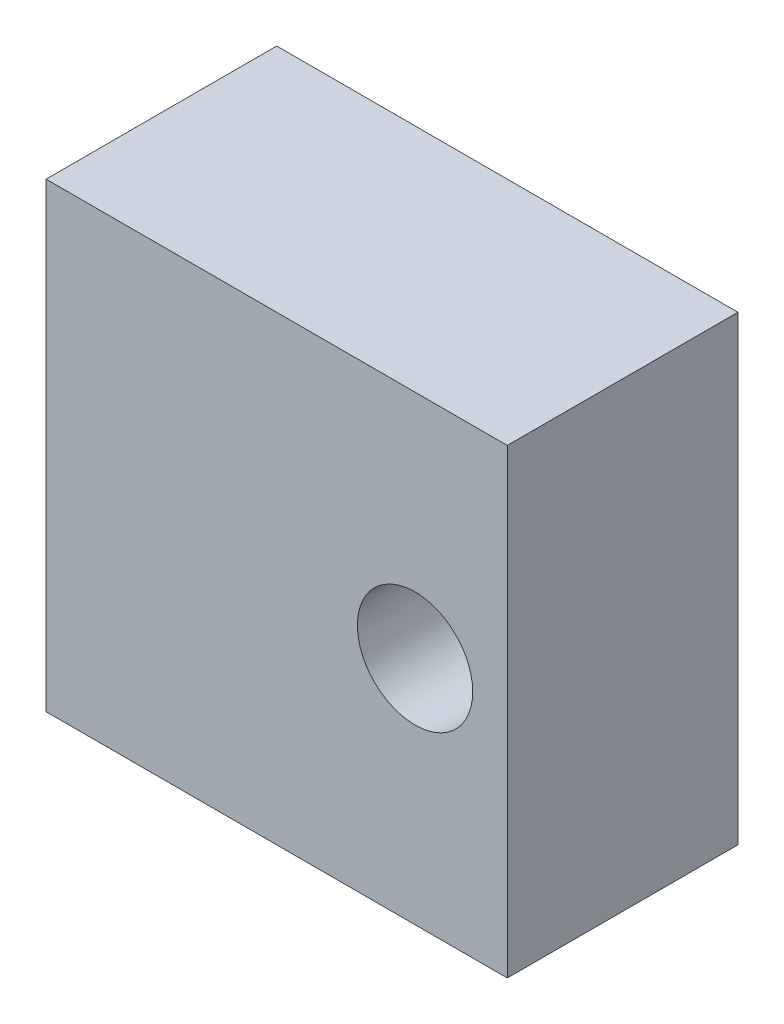
from build123d import *

# Parameters (mm, degrees)
SKETCH_1_W          = 20
SKETCH_1_H          = 20
EXTRUDE_1_DEPTH     = 10
SKETCH_4_R          = 2.5
CUT_EXTRUDE_1_DEPTH = 10


with BuildPart() as part:
    # 草图1 → 凸台-拉伸1 (new body)
    with BuildSketch(Plane.XY):
        with Locations((1.391304348, -3.086956522)):
            Rectangle(SKETCH_1_W, SKETCH_1_H)
    extrude(amount=EXTRUDE_1_DEPTH)

    # 草图4 → 切除-拉伸1 (cut)
    with BuildSketch(Plane.XY.offset(10)):
        with Locations((7.391304348, -3.086956522)):
            Circle(SKETCH_4_R)
    extrude(amount=-CUT_EXTRUDE_1_DEPTH, mode=Mode.SUBTRACT)


solid = part.part
